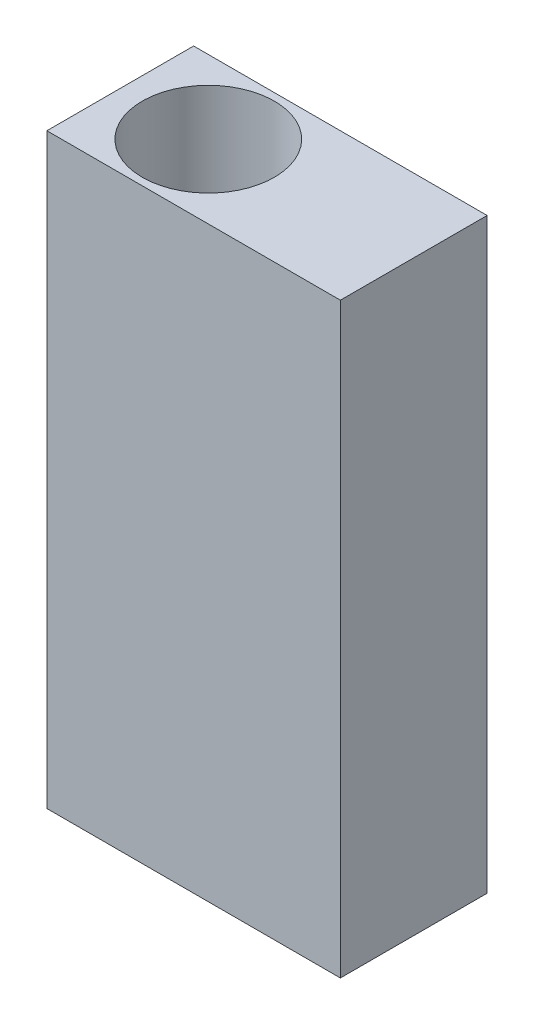
from build123d import *

# Parameters (mm, degrees)
SKETCH1_W           = 20
SKETCH1_H           = 10
SKETCH1_R           = 4.5
BOSS_EXTRUDE1_DEPTH = 40


with BuildPart() as part:
    # Sketch1 → Boss-Extrude1 (new body)
    with BuildSketch(Plane(origin=(0, 0, 0), x_dir=(1, 0, 0), z_dir=(0, 1, 0))):
        with Locations((4, 0)):
            Rectangle(SKETCH1_W, SKETCH1_H)
        Circle(SKETCH1_R, mode=Mode.SUBTRACT)
    extrude(amount=BOSS_EXTRUDE1_DEPTH)


solid = part.part
